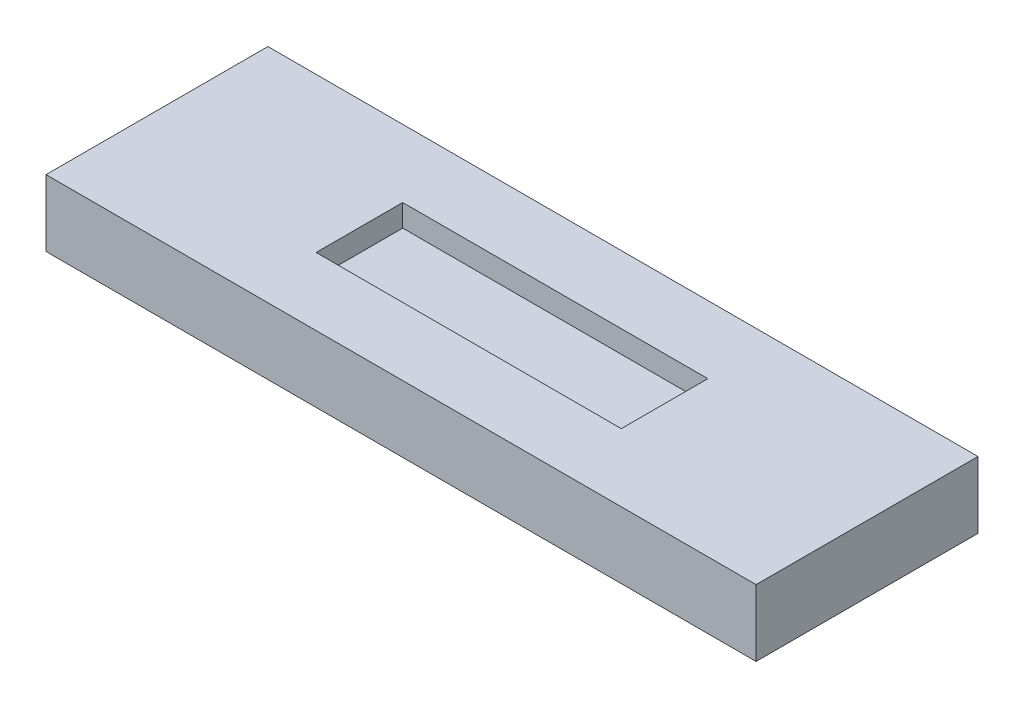
from build123d import *

# Parameters (mm, degrees)
SKETCH_1_W          = 32
SKETCH_1_H          = 10
EXTRUDE_1_DEPTH     = 3
SKETCH_2_W          = 13.75
SKETCH_2_H          = 3.9
CUT_EXTRUDE_1_DEPTH = 1


with BuildPart() as part:
    # 草圖1 → 填料-伸長1 (new body)
    with BuildSketch(Plane(origin=(0, 0, 0), x_dir=(1, 0, 0), z_dir=(0, 1, 0))):
        Rectangle(SKETCH_1_W, SKETCH_1_H)
    extrude(amount=EXTRUDE_1_DEPTH)

    # 草圖2 → 除料-伸長1 (cut)
    with BuildSketch(Plane(origin=(0, 3, 0), x_dir=(1, 0, 0), z_dir=(0, 1, 0))):
        Rectangle(SKETCH_2_W, SKETCH_2_H)
    extrude(amount=-CUT_EXTRUDE_1_DEPTH, mode=Mode.SUBTRACT)


solid = part.part
